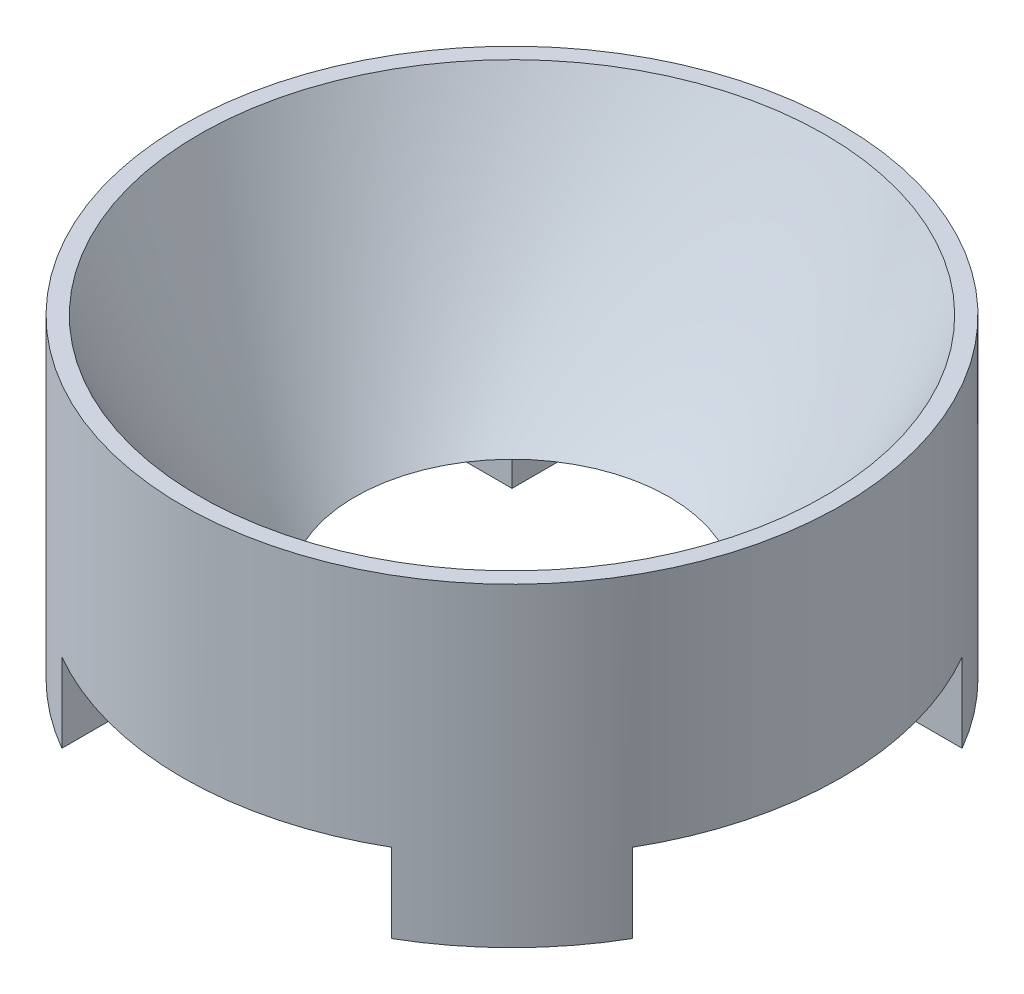
from build123d import *

# Parameters (mm, degrees)
CUT_EXTRUDE1_DEPTH = 1.524


with BuildPart() as part:
    # Sketch1 → Revolve1 (revolve)
    with BuildSketch(Plane.XY, mode=Mode.PRIVATE) as revolve1_sk:
        with BuildLine():
            Line((6.03256665, 6.065311925), (6.35, 6.065311925))
            Line((6.35, 6.065311925), (6.35, 0))
            Line((6.35, 0), (3, 0))
            Line((3, 0), (3, 1.50000046))
            add(Edge.make_bspline(
                [(3, 1.50000046), (4.516283325, 3.01628425), (6.03256665, 6.065311925)],
                knots=[0.189541829, 0.189541829, 0.189541829, 0.293296022, 0.293296022, 0.293296022], degree=2))
        make_face()
    revolve(revolve1_sk.sketch.rotate(Axis((0, -656.299212598, 0), (0, 1, 0)), 90), axis=Axis((0, -656.299212598, 0), (0, 1, 0)))  # turned: the seam where the file's is

    # Sketch2 → Cut-Extrude1 (cut)
    with BuildSketch(Plane.XZ):
        Polygon((-3.175, 13.682823353), (3.175, 13.682823353), (3.175, 3.175), (13.682823353, 3.175), (13.682823353, -3.175), (3.175, -3.175), (3.175, -13.682823353), (-3.175, -13.682823353), (-3.175, -3.175), (-13.682823353, -3.175), (-13.682823353, 3.175), (-3.175, 3.175), align=None)
    extrude(amount=-CUT_EXTRUDE1_DEPTH, mode=Mode.SUBTRACT)


solid = part.part
